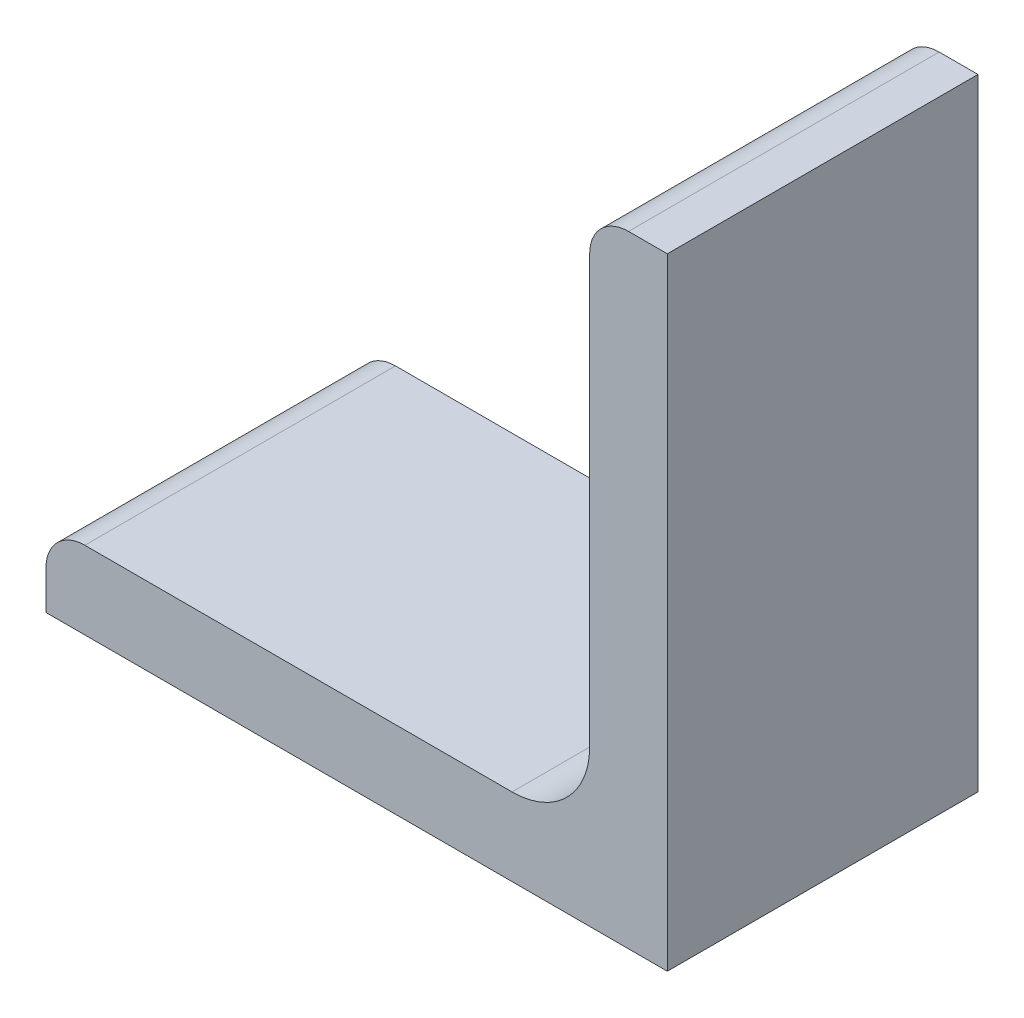
from build123d import *

# Parameters (mm, degrees)
BOSS_EXTRUDE1_DEPTH = 152.4
SKETCH3_W           = 36.131988192
SKETCH3_H           = 294.530449207
CUT_EXTRUDE1_DEPTH  = 156.02325632


with BuildPart() as part:
    # Sketch2 → Boss-Extrude1 (new, symmetric)
    with BuildSketch(Plane.XY):
        with BuildLine():
            Line((-12.7, -12.7), (12.7, -12.7))
            Line((12.7, -12.7), (12.7, 12.7))
            Line((12.7, 12.7), (11.1125, 12.7))
            ThreePointArc((11.1125, 12.7), (9.989967985, 12.235032015), (9.525, 11.1125))
            Line((9.525, 11.1125), (9.525, -6.35))
            ThreePointArc((9.525, -6.35), (8.59506403, -8.59506403), (6.35, -9.525))
            Line((6.35, -9.525), (-11.1125, -9.525))
            ThreePointArc((-11.1125, -9.525), (-12.235032015, -9.989967985), (-12.7, -11.1125))
            Line((-12.7, -11.1125), (-12.7, -12.7))
        make_face()
    extrude(amount=BOSS_EXTRUDE1_DEPTH, both=True)

    # Sketch3 → Cut-Extrude1 (cut, through all)
    with BuildSketch(Plane.XZ.offset(12.7)):
        with Locations((-0.553949025, -7.565224603)):
            Rectangle(SKETCH3_W, SKETCH3_H)
    extrude(amount=-CUT_EXTRUDE1_DEPTH, mode=Mode.SUBTRACT)


solid = part.part
